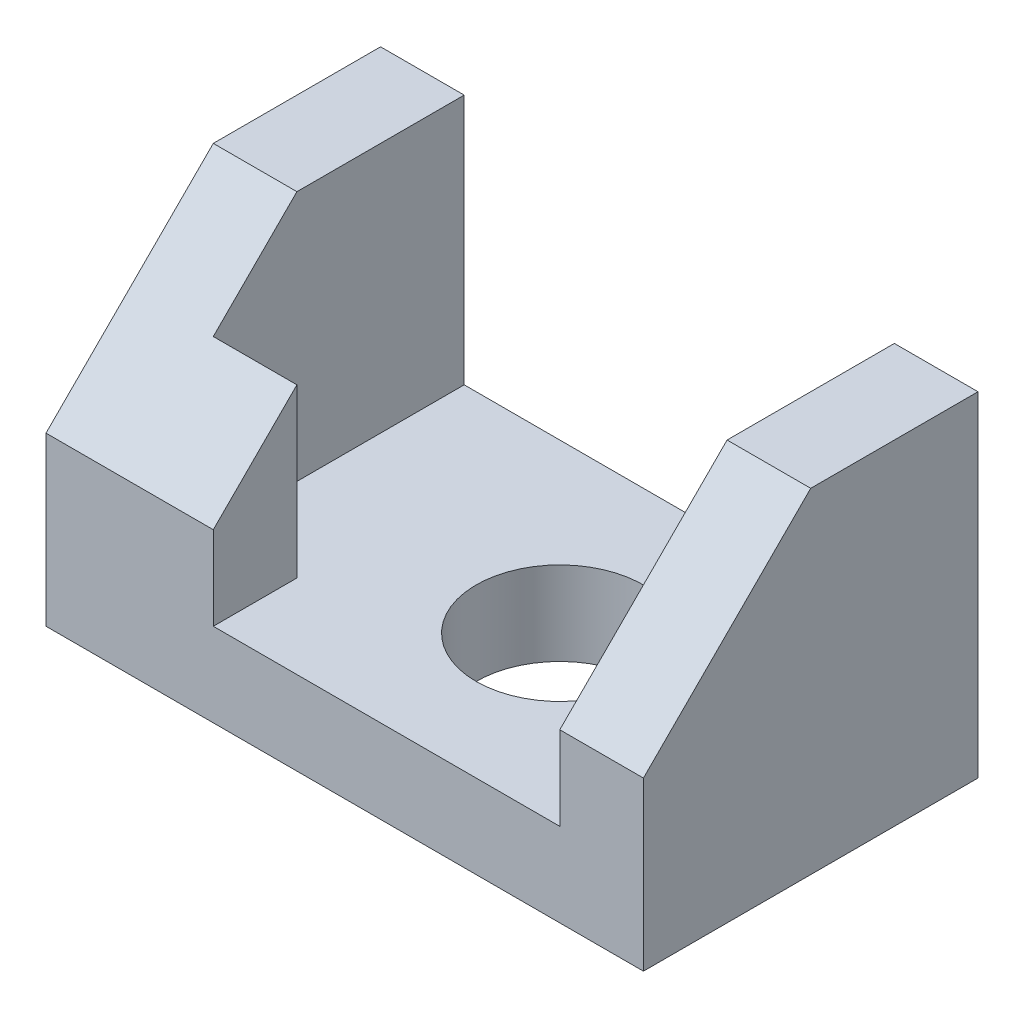
from build123d import *

# Parameters (mm, degrees)
SKETCH1_R           = 7
BOSS_EXTRUDE1_DEPTH = 7
SKETCH1_3_W         = 7
SKETCH1_3_H         = 28
BOSS_EXTRUDE2_DEPTH = 28
CHAMFER1_SIZE       = 14


with BuildPart() as part:
    # Sketch1 → Boss-Extrude1 (new body)
    with BuildSketch(Plane(origin=(0, 0, 0), x_dir=(1, 0, 0), z_dir=(0, 1, 0))):
        Polygon((18, -14), (18, 14), (-18, 14), (-18, -7), (-11, -7), (-11, -14), align=None)
        with Locations((4, 0)):
            Circle(SKETCH1_R, mode=Mode.SUBTRACT)
    extrude(amount=BOSS_EXTRUDE1_DEPTH)

    # Sketch1_3 → Boss-Extrude2 (add)
    with BuildSketch(Plane(origin=(0, 0, 0), x_dir=(1, 0, 0), z_dir=(0, 1, 0))):
        with Locations((21.5, 0)):
            Rectangle(SKETCH1_3_W, SKETCH1_3_H)
        Polygon((-18, -7), (-18, 14), (-25, 14), (-25, -14), (-11, -14), (-11, -7), align=None)
    extrude(amount=BOSS_EXTRUDE2_DEPTH)

    # Chamfer1
    chamfer1_edges = [part.edges().sort_by_distance(p)[0] for p in [
        (-18, 28, 14),
        (21.5, 28, 14),
    ]]
    chamfer(chamfer1_edges, length=CHAMFER1_SIZE)


solid = part.part
